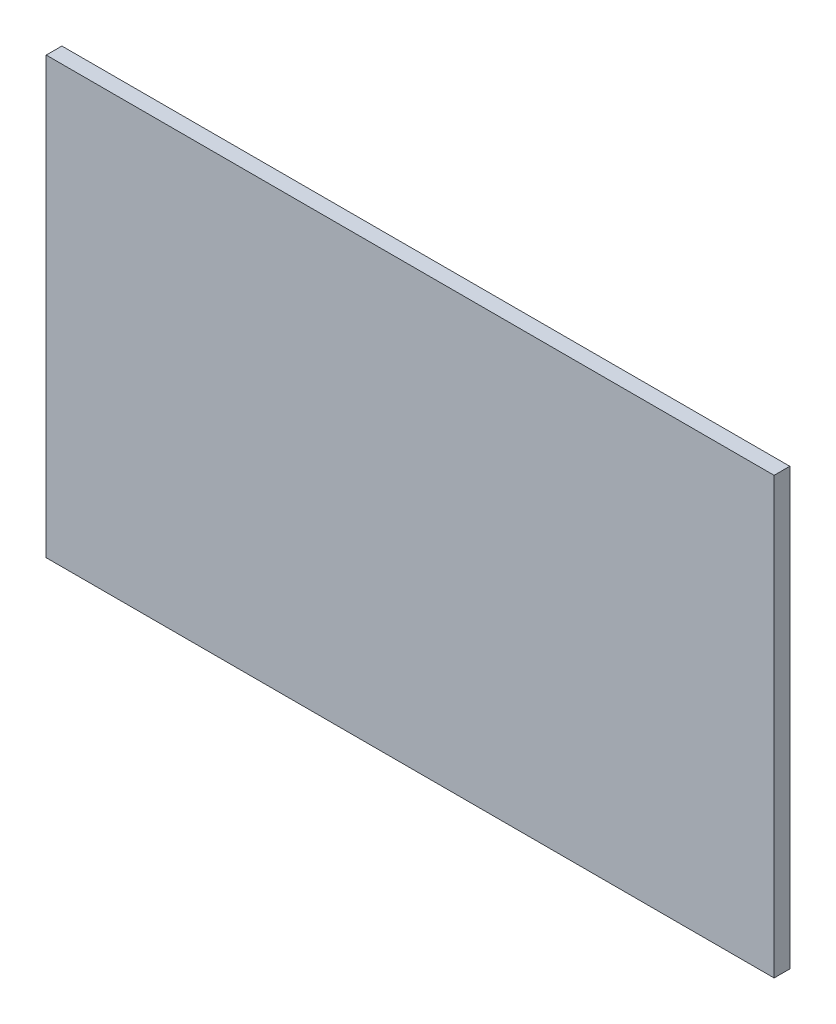
from build123d import *

# Parameters (mm, degrees)
SKETCH1_W           = 418
SKETCH1_H           = 250
BOSS_EXTRUDE1_DEPTH = 9


with BuildPart() as part:
    # Sketch1 → Boss-Extrude1 (new body)
    with BuildSketch(Plane.XY):
        with Locations((209, 125)):
            Rectangle(SKETCH1_W, SKETCH1_H)
    extrude(amount=BOSS_EXTRUDE1_DEPTH)


solid = part.part
